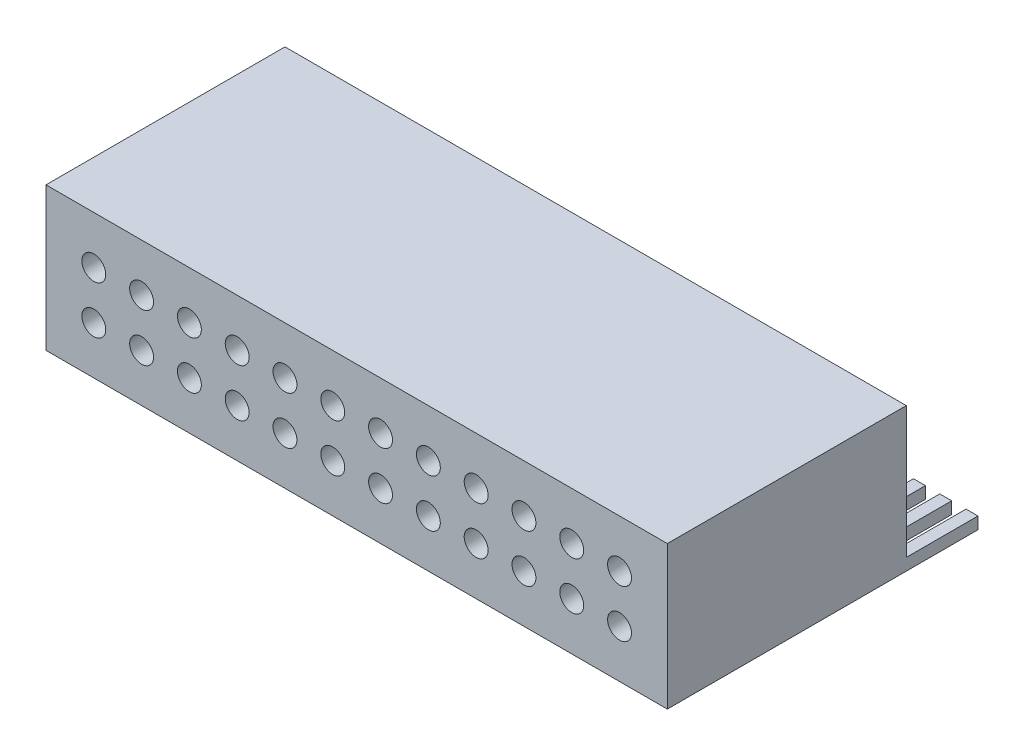
from build123d import *

# Parameters (mm, degrees)
SKETCH2_W           = 26
SKETCH2_H           = 6
BOSS_EXTRUDE1_DEPTH = 10
SKETCH3_R           = 0.5
CUT_EXTRUDE1_DEPTH  = 5
SKETCH4_W           = 0.5
SKETCH4_H           = 3
BOSS_EXTRUDE2_DEPTH = 0.5


with BuildPart() as part:
    # Sketch2 → Boss-Extrude1 (new body)
    with BuildSketch(Plane.XY):
        with Locations((13, 3)):
            Rectangle(SKETCH2_W, SKETCH2_H)
    extrude(amount=BOSS_EXTRUDE1_DEPTH)

    # Sketch3 → Cut-Extrude1 (cut)
    with BuildSketch(Plane.XY.offset(10)):
        with Locations((2, 2)):
            Circle(SKETCH3_R)
        with Locations((4, 2)):
            Circle(SKETCH3_R)
        with Locations((6, 2)):
            Circle(SKETCH3_R)
        with Locations((8, 2)):
            Circle(SKETCH3_R)
        with Locations((10, 2)):
            Circle(SKETCH3_R)
        with Locations((12, 2)):
            Circle(SKETCH3_R)
        with Locations((14, 2)):
            Circle(SKETCH3_R)
        with Locations((16, 2)):
            Circle(SKETCH3_R)
        with Locations((18, 2)):
            Circle(SKETCH3_R)
        with Locations((20, 2)):
            Circle(SKETCH3_R)
        with Locations((22, 2)):
            Circle(SKETCH3_R)
        with Locations((24, 2)):
            Circle(SKETCH3_R)
        with Locations((24, 4)):
            Circle(SKETCH3_R)
        with Locations((22, 4)):
            Circle(SKETCH3_R)
        with Locations((20, 4)):
            Circle(SKETCH3_R)
        with Locations((18, 4)):
            Circle(SKETCH3_R)
        with Locations((16, 4)):
            Circle(SKETCH3_R)
        with Locations((14, 4)):
            Circle(SKETCH3_R)
        with Locations((12, 4)):
            Circle(SKETCH3_R)
        with Locations((10, 4)):
            Circle(SKETCH3_R)
        with Locations((8, 4)):
            Circle(SKETCH3_R)
        with Locations((6, 4)):
            Circle(SKETCH3_R)
        with Locations((4, 4)):
            Circle(SKETCH3_R)
        with Locations((2, 4)):
            Circle(SKETCH3_R)
    extrude(amount=-CUT_EXTRUDE1_DEPTH, mode=Mode.SUBTRACT)

    # Sketch4 → Boss-Extrude2 (add)
    with BuildSketch(Plane(origin=(0, 0, 0), x_dir=(-1, 0, 0), z_dir=(0, -1, 0))):
        with Locations((-24.65, 1.5)):
            Rectangle(SKETCH4_W, SKETCH4_H)
        with Locations((-25.75, 1.5)):
            Rectangle(SKETCH4_W, SKETCH4_H)
        with Locations((-23.55, 1.5)):
            Rectangle(SKETCH4_W, SKETCH4_H)
        with Locations((-22.45, 1.5)):
            Rectangle(SKETCH4_W, SKETCH4_H)
        with Locations((-21.35, 1.5)):
            Rectangle(SKETCH4_W, SKETCH4_H)
        with Locations((-20.25, 1.5)):
            Rectangle(SKETCH4_W, SKETCH4_H)
        with Locations((-19.15, 1.5)):
            Rectangle(SKETCH4_W, SKETCH4_H)
        with Locations((-18.05, 1.5)):
            Rectangle(SKETCH4_W, SKETCH4_H)
        with Locations((-16.95, 1.5)):
            Rectangle(SKETCH4_W, SKETCH4_H)
        with Locations((-15.85, 1.5)):
            Rectangle(SKETCH4_W, SKETCH4_H)
        with Locations((-14.75, 1.5)):
            Rectangle(SKETCH4_W, SKETCH4_H)
        with Locations((-13.65, 1.5)):
            Rectangle(SKETCH4_W, SKETCH4_H)
        with Locations((-12.55, 1.5)):
            Rectangle(SKETCH4_W, SKETCH4_H)
        with Locations((-11.45, 1.5)):
            Rectangle(SKETCH4_W, SKETCH4_H)
        with Locations((-10.35, 1.5)):
            Rectangle(SKETCH4_W, SKETCH4_H)
        with Locations((-9.25, 1.5)):
            Rectangle(SKETCH4_W, SKETCH4_H)
        with Locations((-8.15, 1.5)):
            Rectangle(SKETCH4_W, SKETCH4_H)
        with Locations((-7.05, 1.5)):
            Rectangle(SKETCH4_W, SKETCH4_H)
        with Locations((-5.95, 1.5)):
            Rectangle(SKETCH4_W, SKETCH4_H)
        with Locations((-4.85, 1.5)):
            Rectangle(SKETCH4_W, SKETCH4_H)
        with Locations((-3.75, 1.5)):
            Rectangle(SKETCH4_W, SKETCH4_H)
        with Locations((-2.65, 1.5)):
            Rectangle(SKETCH4_W, SKETCH4_H)
        with Locations((-1.55, 1.5)):
            Rectangle(SKETCH4_W, SKETCH4_H)
        with Locations((-0.45, 1.5)):
            Rectangle(SKETCH4_W, SKETCH4_H)
    extrude(amount=-BOSS_EXTRUDE2_DEPTH)


solid = part.part
